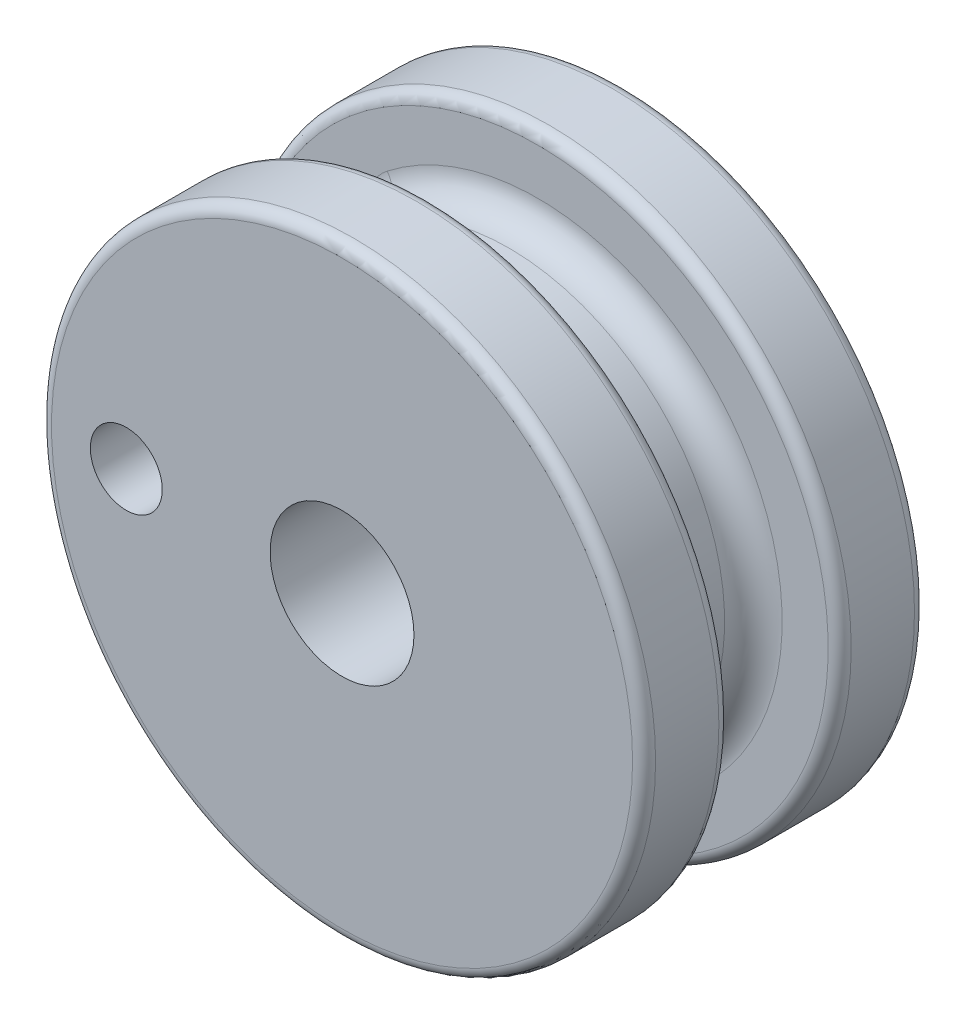
from build123d import *

# Parameters (mm, degrees)
BOSS_EXTRUDE1_START            = -15.24
SKETCH1_R                      = 9.525
SKETCH1_R_2                    = 3.175
BOSS_EXTRUDE1_DEPTH            = 6.223
SKETCH3_R                      = 13.335
SKETCH3_R_2                    = 3.175
BOSS_EXTRUDE2_DEPTH            = 3.81
F_1_8_0_1250_DOWEL_HOLE1_D     = 3.175
CUT_EXTRUDE2_REACH             = 8.223
SKETCH9_W                      = 6.35
SKETCH9_H                      = 14.199031658
CUT_EXTRUDE2_DIRECTION_2_REACH = 8.223
FILLET2_R                      = 1.27
FILLET3_R                      = 0.508


with BuildPart() as part:
    # Sketch1 → Boss-Extrude1 (new body, symmetric)
    with BuildSketch(Plane.XY.offset(BOSS_EXTRUDE1_START)):
        with Locations((-38.179733534, 0)):
            Circle(SKETCH1_R)
        with Locations((-38.179733534, 0)):
            Circle(SKETCH1_R_2, mode=Mode.SUBTRACT)
    extrude(amount=BOSS_EXTRUDE1_DEPTH, both=True)

    # Sketch3 → Boss-Extrude2 (add)
    with BuildSketch(Plane.XY.offset(-9.017)):
        with Locations((-38.179733534, 0)):
            Circle(SKETCH3_R)
        with Locations((-38.179733534, 0)):
            Circle(SKETCH3_R_2, mode=Mode.SUBTRACT)
    boss_extrude2 = extrude(amount=-BOSS_EXTRUDE2_DEPTH)

    # Mirror1: Boss-Extrude2 across plane
    add(boss_extrude2.mirror(Plane.XY.offset(-15.24)))

    # 1/8 (0.1250) Dowel Hole1 (through all)
    with Locations(Plane(origin=(0, 0, -21.463), x_dir=(1, 0, 0), z_dir=(0, 0, -1))):
        with Locations((-47.704733534, 0)):
            Hole(F_1_8_0_1250_DOWEL_HOLE1_D / 2)

    # Cut-Extrude2: up to this face of the body (flat: up to its plane)
    cut_extrude2_end = Plane(part.part.faces().sort_by_distance((-51.137562777, 0, -17.653))[0])
    # Sketch9 → Cut-Extrude2 (cut, up to the picked face)
    with BuildSketch(Plane.XY.offset(-15.24), mode=Mode.PRIVATE) as cut_extrude2_sk1:
        with Locations((-47.704733534, 0)):
            Rectangle(SKETCH9_W, SKETCH9_H)
    cut_extrude2_tool1 = split(extrude(cut_extrude2_sk1.sketch, amount=-CUT_EXTRUDE2_REACH, mode=Mode.PRIVATE), bisect_by=cut_extrude2_end, keep=Keep.BOTH, mode=Mode.PRIVATE)
    add(cut_extrude2_tool1.solids().sort_by_distance((-47.704734, 0, -15.24))[0], mode=Mode.SUBTRACT)

    # Cut-Extrude2 direction 2: up to this face of the body (flat: up to its plane)
    cut_extrude2_direction_2_end = Plane(part.part.faces().sort_by_distance((-51.137562777, 0, -12.827))[0])
    # Sketch9 → Cut-Extrude2 direction 2 (cut, up to the picked face)
    with BuildSketch(Plane.XY.offset(-15.24), mode=Mode.PRIVATE) as cut_extrude2_direction_2_sk1:
        with Locations((-47.704733534, 0)):
            Rectangle(SKETCH9_W, SKETCH9_H)
    cut_extrude2_direction_2_tool1 = split(extrude(cut_extrude2_direction_2_sk1.sketch, amount=CUT_EXTRUDE2_DIRECTION_2_REACH, mode=Mode.PRIVATE), bisect_by=cut_extrude2_direction_2_end, keep=Keep.BOTH, mode=Mode.PRIVATE)
    add(cut_extrude2_direction_2_tool1.solids().sort_by_distance((-47.704734, 0, -15.24))[0], mode=Mode.SUBTRACT)

    # Fillet2
    fillet2_edges = [part.edges().sort_by_distance(p)[0] for p in [
        (-28.654733534, 0, -17.653),
        (-28.654733534, 0, -12.827),
        (-44.529733534, 0, -12.827),
        (-44.529733534, -7.099515829, -15.24),
        (-44.529733534, 0, -17.653),
        (-44.529733534, 7.099515829, -15.24),
    ]]
    fillet(fillet2_edges, radius=FILLET2_R)

    # Fillet3
    fillet3_edges = [part.edges().sort_by_distance(p)[0] for p in [
        (-51.514733534, 0, -9.017),
        (-51.514733534, 0, -12.827),
        (-51.514733534, 0, -17.653),
        (-51.514733534, 0, -21.463),
    ]]
    fillet(fillet3_edges, radius=FILLET3_R)


solid = part.part
